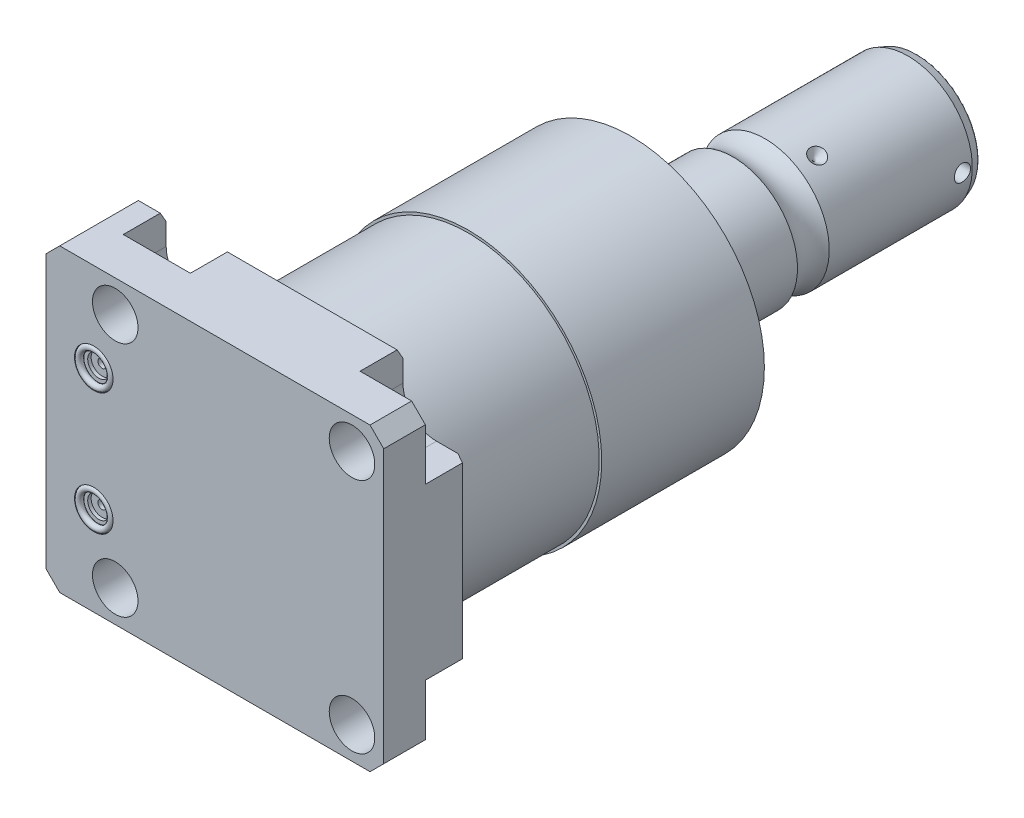
from build123d import *

# Parameters (mm, degrees)
SKETCH1_W            = 99.9998
SKETCH1_H            = 88.9
EXTRUDE1_DEPTH       = 25.019
SKETCH2_R            = 6.7437
CUT_EXTRUDE1_DEPTH   = 27.5209
LPATTERN1_COUNT      = 2
LPATTERN1_PITCH      = 70.104
LPATTERN1_COUNT_DIR2 = 2
LPATTERN1_PITCH_DIR2 = 70.104
CUT_EXTRUDE2_DEPTH   = 12.7
SKETCH6_R            = 5.7023
CUT_EXTRUDE3_DEPTH   = 1.4478
SKETCH7_R            = 3.2512
CUT_EXTRUDE4_DEPTH   = 1.016
SKETCH8_R            = 1.2446
CUT_EXTRUDE5_DEPTH   = 11.9888
SKETCH9_R            = 0.9271
LPATTERN3_COUNT      = 2
LPATTERN3_PITCH      = 36.2204
CHAMFER1_SIZE        = 4.064
CHAMFER2_SIZE        = 3.0226
CHAMFER2_SIZE2       = 1.745098924
SKETCH14_R           = 39.5224
EXTRUDE2_DEPTH       = 96.393
SKETCH15_OUTSIDE_W   = 138.19
SKETCH15_OUTSIDE_H   = 127.09
SKETCH15_OUTSIDE_R   = 38.7858
CUT_EXTRUDE9_DEPTH   = 44.45
SKETCH19_R           = 7.112
EXTRUDE3_DEPTH       = 1.524
SKETCH20_R           = 16.129
SKETCH20_R_2         = 15.748
CUT_EXTRUDE10_DEPTH  = 0.254
CUT_EXTRUDE11_DEPTH  = 8.001
CIRPATTERN1_COUNT    = 3
SKETCH23_W           = 3.81
SKETCH23_H           = 2.413
FILLET1_R            = 0.635


with BuildPart() as part:
    # Sketch1 → Extrude1 (new body)
    with BuildSketch(Plane.XY):
        with Locations((-5.5499, 0)):
            Rectangle(SKETCH1_W, SKETCH1_H)
    extrude(amount=EXTRUDE1_DEPTH)

    # Sketch2 → Cut-Extrude1 (cut)
    with BuildSketch(Plane(origin=(0, 0, 0), x_dir=(-1, 0, 0), z_dir=(0, 0, -1))):
        with Locations((-35.052, -35.052)):
            Circle(SKETCH2_R)
    cut_extrude1 = extrude(amount=-CUT_EXTRUDE1_DEPTH, mode=Mode.SUBTRACT)

    # LPattern1: Cut-Extrude1 2 × 2
    with Locations(*[(-j * LPATTERN1_PITCH_DIR2, i * LPATTERN1_PITCH, 0) for i in range(LPATTERN1_COUNT) for j in range(LPATTERN1_COUNT_DIR2) if (i, j) != (0, 0)]):
        add(cut_extrude1, mode=Mode.SUBTRACT)

    # Sketch3 → Cut-Extrude2 (cut)
    with BuildSketch(Plane(origin=(0, 0, 0), x_dir=(-1, 0, 0), z_dir=(0, 0, -1))):
        with BuildLine():
            Line((-35.052, -25.1206), (-44.45, -25.1206))
            Line((-44.45, -25.1206), (-44.45, -44.45))
            Line((-44.45, -44.45), (-25.1206, -44.45))
            Line((-25.1206, -44.45), (-25.1206, -35.052))
            ThreePointArc((-25.1206, -35.052), (-28.029439713, -28.029439713), (-35.052, -25.1206))
        make_face()
        with BuildLine():
            Line((-44.45, 25.1206), (-44.45, 44.45))
            Line((-44.45, 44.45), (-25.1206, 44.45))
            Line((-25.1206, 44.45), (-25.1206, 35.052))
            ThreePointArc((-25.1206, 35.052), (-28.029439713, 28.029439713), (-35.052, 25.1206))
            Line((-35.052, 25.1206), (-44.45, 25.1206))
        make_face()
        with BuildLine():
            Line((25.1206, 44.45), (25.1206, 35.052))
            ThreePointArc((25.1206, 35.052), (35.052, 25.1206), (44.9834, 35.052))
            Line((44.9834, 35.052), (44.9834, 44.45))
            Line((44.9834, 44.45), (25.1206, 44.45))
        make_face()
        with BuildLine():
            Line((44.9834, -44.45), (25.1206, -44.45))
            Line((25.1206, -44.45), (25.1206, -35.052))
            ThreePointArc((25.1206, -35.052), (35.052, -25.1206), (44.9834, -35.052))
            Line((44.9834, -35.052), (44.9834, -44.45))
        make_face()
    extrude(amount=-CUT_EXTRUDE2_DEPTH, mode=Mode.SUBTRACT)

    # S2D0007 → Cut-Revolve1 (revolve, cut)
    with BuildSketch(Plane(origin=(-55.5498, -13.0048, 12.0142), x_dir=(0, 1, 0), z_dir=(0, 0, 1)), mode=Mode.PRIVATE) as cut_revolve1_sk:
        Polygon((0, 0), (10.4775, 0), (10.4775, -0.254), (6.1849, -0.254), (5.642306865, -2.8067), (4.9784, -3.470606865), (4.9784, -14.224), (0, -14.224), align=None)
    revolve(cut_revolve1_sk.sketch.rotate(Axis((-40.6146, -13.0048, 12.0142), (-1, 0, 0)), 90), axis=Axis((-40.6146, -13.0048, 12.0142), (-1, 0, 0)), mode=Mode.SUBTRACT)  # turned: the seam where the file's is

    # Sketch5 → Cut-Revolve2 (revolve, cut)
    with BuildSketch(Plane(origin=(-55.5498, 13.0048, 12.0142), x_dir=(0, 1, 0), z_dir=(0, 0, 1)), mode=Mode.PRIVATE) as cut_revolve2_sk:
        Polygon((0, 0), (10.4775, 0), (10.4775, -0.254), (6.1849, -0.254), (5.642306865, -2.8067), (4.9784, -3.470606865), (4.9784, -14.224), (0, -14.224), align=None)
    revolve(cut_revolve2_sk.sketch.rotate(Axis((-40.6146, 13.0048, 12.0142), (-1, 0, 0)), 90), axis=Axis((-40.6146, 13.0048, 12.0142), (-1, 0, 0)), mode=Mode.SUBTRACT)  # turned: the seam where the file's is

    # Sketch6 → Cut-Extrude3 (cut)
    with BuildSketch(Plane.XY.offset(25.019)):
        with Locations((-41.402, -18.1102)):
            Circle(SKETCH6_R)
        with Locations((-41.402, 18.1102)):
            Circle(SKETCH6_R)
    extrude(amount=-CUT_EXTRUDE3_DEPTH, mode=Mode.SUBTRACT)

    # Sketch7 → Cut-Extrude4 (cut)
    with BuildSketch(Plane.XY.offset(23.5712)):
        with Locations((-41.402, 18.1102)):
            Circle(SKETCH7_R)
        with Locations((-41.402, -18.1102)):
            Circle(SKETCH7_R)
    extrude(amount=-CUT_EXTRUDE4_DEPTH, mode=Mode.SUBTRACT)

    # Sketch8 → Cut-Extrude5 (cut)
    with BuildSketch(Plane.XY.offset(22.5552)):
        with Locations((-41.402, 18.1102)):
            Circle(SKETCH8_R)
        with Locations((-41.402, -18.1102)):
            Circle(SKETCH8_R)
    extrude(amount=-CUT_EXTRUDE5_DEPTH, mode=Mode.SUBTRACT)

    # Chamfer1
    chamfer1_edges = [part.edges().sort_by_distance(p)[0] for p in [
        (-55.5498, 44.45, 12.5095),
        (44.45, 44.45, 18.8595),
        (44.45, -44.45, 18.8595),
        (-55.5498, -44.45, 12.5095),
    ]]
    chamfer(chamfer1_edges, length=CHAMFER1_SIZE)

    # Chamfer2
    chamfer2_edges = [part.edges().sort_by_distance(p)[0] for p in [
        (-48.2346, -44.45, 0),
        (44.45, 0, 0),
        (0, 44.45, 0),
        (-48.2346, 44.45, 0),
        (0, -44.45, 0),
    ]]
    chamfer2_side = [part.faces().sort_by_distance(p)[0] for p in [
        (-6.590443221, 0, 0),
    ]]
    chamfer(chamfer2_edges, length=CHAMFER2_SIZE, length2=CHAMFER2_SIZE2, reference=chamfer2_side[0])

    # Sketch14 → Extrude2 (add)
    with BuildSketch(Plane(origin=(0, 0, 0), x_dir=(-1, 0, 0), z_dir=(0, 0, -1))):
        Circle(SKETCH14_R)
    extrude(amount=EXTRUDE2_DEPTH)

    # Sketch15 outside → Cut-Extrude9 (cut)
    with BuildSketch(Plane(origin=(0, 0, 0), x_dir=(-1, 0, 0), z_dir=(0, 0, -1))):
        with Locations((5.55, 0)):
            Rectangle(SKETCH15_OUTSIDE_W, SKETCH15_OUTSIDE_H)
        Circle(SKETCH15_OUTSIDE_R, mode=Mode.SUBTRACT)
    extrude(amount=CUT_EXTRUDE9_DEPTH, mode=Mode.SUBTRACT)

    # Sketch16 → Cut-Revolve3 (revolve, cut)
    with BuildSketch(Plane(origin=(0, 0, 0), x_dir=(0, 0, 1), z_dir=(1, 0, 0)), mode=Mode.PRIVATE) as cut_revolve3_sk:
        Polygon((-96.393, 25.4), (-92.608914325, 39.5224), (-96.393, 39.5224), align=None)
    revolve(cut_revolve3_sk.sketch.rotate(Axis((0, 0, -96.582204284), (0, 0, 1)), 270), axis=Axis((0, 0, -96.582204284), (0, 0, 1)), mode=Mode.SUBTRACT)  # turned: the seam where the file's is

    # Sketch17 → Revolve3 (revolve)
    with BuildSketch(Plane(origin=(0, 0, 0), x_dir=(0, 0, 1), z_dir=(1, 0, 0)), mode=Mode.PRIVATE) as revolve3_sk:
        with BuildLine():
            Line((-96.393, 0), (-96.393, 19.05))
            Line((-96.393, 19.05), (-122.87710643, 19.05))
            ThreePointArc((-122.87710643, 19.05), (-127.5842, 17.5006), (-132.29129357, 19.05))
            Line((-132.29129357, 19.05), (-174.6504, 19.05))
            Line((-174.6504, 19.05), (-177.5714, 17.986842946))
            Line((-177.5714, 17.986842946), (-177.5714, 0))
            Line((-177.5714, 0), (-96.393, 0))
        make_face()
    revolve(revolve3_sk.sketch.rotate(Axis((0, 0, -180.9369), (0, 0, 1)), 270), axis=Axis((0, 0, -180.9369), (0, 0, 1)))  # turned: the seam where the file's is

    # Sketch19 → Extrude3 (add)
    with BuildSketch(Plane.ZY.offset(55.2958)):
        with Locations(Location((12.0142, -13.0048, 0), (0, 0, 180))):  # turned: the seam where the file's is
            Circle(SKETCH19_R)
    extrude(amount=EXTRUDE3_DEPTH)

    # Sketch20 → Cut-Extrude10 (cut)
    with BuildSketch(Plane(origin=(0, 0, -177.5714), x_dir=(-1, 0, 0), z_dir=(0, 0, -1))):
        Circle(SKETCH20_R)
        Circle(SKETCH20_R_2, mode=Mode.SUBTRACT)
    extrude(amount=-CUT_EXTRUDE10_DEPTH, mode=Mode.SUBTRACT)

    # Sketch21 → Cut-Extrude11 (cut)
    with BuildSketch(Plane(origin=(0, 0, -177.5714), x_dir=(-1, 0, 0), z_dir=(0, 0, -1))):
        Polygon((4.619379504, 0), (2.309689752, 4.0005), (-2.309689752, 4.0005), (-4.619379504, 0), (-2.309689752, -4.0005), (2.309689752, -4.0005), align=None)
    extrude(amount=-CUT_EXTRUDE11_DEPTH, mode=Mode.SUBTRACT)

    # Sketch22 → Cut-Revolve4 (revolve, cut)
    with BuildSketch(Plane(origin=(0, 0, 0), x_dir=(1, 0, 0), z_dir=(0, 1, 0)), mode=Mode.PRIVATE) as cut_revolve4_sk:
        Polygon((-19.05, 140.6652), (-16.637, 138.2522), (-19.05, 138.2522), align=None)
    cut_revolve4 = revolve(cut_revolve4_sk.sketch.rotate(Axis((-42.100308337, 0, -138.2522), (1, 0, 0)), 180), axis=Axis((-42.100308337, 0, -138.2522), (1, 0, 0)), mode=Mode.SUBTRACT)  # turned: the seam where the file's is

    # CirPattern1: Cut-Revolve4 ×3 about axis
    cirpattern1_axis = Axis((0, 0, -180.9369), (0, 0, -1))
    for i in range(1, CIRPATTERN1_COUNT):
        add(cut_revolve4.rotate(cirpattern1_axis, i * 360 / CIRPATTERN1_COUNT), mode=Mode.SUBTRACT)

    # Sketch23 → Cut-Revolve5 (revolve, cut)
    with BuildSketch(Plane(origin=(0, 0, 0), x_dir=(1, 0, 0), z_dir=(0, 1, 0)), mode=Mode.PRIVATE) as cut_revolve5_sk:
        with Locations((17.145, 172.9359)):
            Rectangle(SKETCH23_W, SKETCH23_H)
    revolve(cut_revolve5_sk.sketch.rotate(Axis((-1.044996547, 0, -171.7294), (1, 0, 0)), 180), axis=Axis((-1.044996547, 0, -171.7294), (1, 0, 0)), mode=Mode.SUBTRACT)  # turned: the seam where the file's is

    # Fillet1
    fillet1_edges = [part.edges().sort_by_distance(p)[0] for p in [
        (17.986842946, 0, -177.5714),
    ]]
    fillet(fillet1_edges, radius=FILLET1_R)


with BuildPart() as body_2:
    # Sketch9 → Revolve1 (revolve)
    with BuildSketch(Plane(origin=(-41.656, 18.1102, 23.5712), x_dir=(1, 0, 0), z_dir=(0, 1, 0))):
        with Locations((5.0292, -0.9271)):
            Circle(SKETCH9_R)
    revolve(axis=Axis((-41.402, 18.1102, 25.51811), (0, 0, -1)))


with BuildPart() as lpattern3_1:
    # LPattern3: pattern copy
    add(body_2.part.moved(Location(Vector(0, -1, 0) * (1 * LPATTERN3_PITCH))))


solid = Compound([part.part, body_2.part, lpattern3_1.part])
